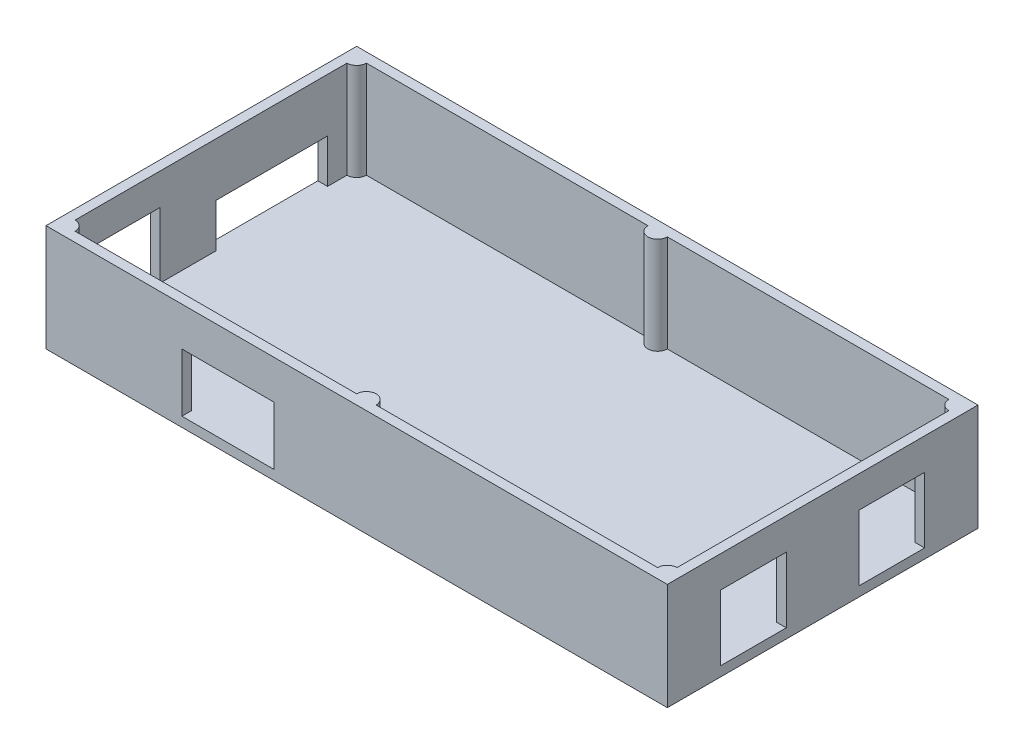
from build123d import *

# Parameters (mm, degrees)
SKETCH3_W           = 128
SKETCH3_H           = 64
BOSS_EXTRUDE1_DEPTH = 22
BOSS_EXTRUDE3_DEPTH = 2
CUT_EXTRUDE1_REACH  = 135.761
SKETCH5_W           = 13.5
SKETCH5_H           = 13.5
SKETCH6_W           = 23
SKETCH6_H           = 9
SKETCH6_W_2         = 13.5
SKETCH6_H_2         = 13.5
CUT_EXTRUDE2_DEPTH  = 2
SKETCH7_W           = 19
SKETCH7_H           = 12
CUT_EXTRUDE3_DEPTH  = 2


with BuildPart() as part:
    # Sketch3 → Boss-Extrude1 (new body)
    with BuildSketch(Plane(origin=(0, 0, 0), x_dir=(1, 0, 0), z_dir=(0, 1, 0))):
        Rectangle(SKETCH3_W, SKETCH3_H)
        with BuildLine():
            Line((2, 30), (60, 30))
            ThreePointArc((60, 30), (60.585786438, 28.585786438), (62, 28))
            Line((62, 28), (62, -28))
            ThreePointArc((62, -28), (60.585786438, -28.585786438), (60, -30))
            Line((60, -30), (2, -30))
            ThreePointArc((2, -30), (0, -28), (-2, -30))
            Line((-2, -30), (-60, -30))
            ThreePointArc((-60, -30), (-60.585786438, -28.585786438), (-62, -28))
            Line((-62, -28), (-62, 28))
            ThreePointArc((-62, 28), (-60.585786438, 28.585786438), (-60, 30))
            Line((-60, 30), (-2, 30))
            ThreePointArc((-2, 30), (0, 28), (2, 30))
        make_face(mode=Mode.SUBTRACT)
    extrude(amount=BOSS_EXTRUDE1_DEPTH)

    # Sketch3_5 → Boss-Extrude3 (add)
    with BuildSketch(Plane(origin=(0, 0, 0), x_dir=(1, 0, 0), z_dir=(0, 1, 0))):
        with BuildLine():
            ThreePointArc((62, 28), (60.585786438, 28.585786438), (60, 30))
            Line((60, 30), (2, 30))
            ThreePointArc((2, 30), (0, 28), (-2, 30))
            Line((-2, 30), (-60, 30))
            ThreePointArc((-60, 30), (-60.585786438, 28.585786438), (-62, 28))
            Line((-62, 28), (-62, -28))
            ThreePointArc((-62, -28), (-60.585786438, -28.585786438), (-60, -30))
            Line((-60, -30), (-2, -30))
            ThreePointArc((-2, -30), (0, -28), (2, -30))
            Line((2, -30), (60, -30))
            ThreePointArc((60, -30), (60.585786438, -28.585786438), (62, -28))
            Line((62, -28), (62, 28))
        make_face()
    extrude(amount=BOSS_EXTRUDE3_DEPTH)

    # Sketch5 → Cut-Extrude1 (cut, up to next)
    with BuildSketch(Plane(origin=(64, 0, 0), x_dir=(0, 0, -1), z_dir=(1, 0, 0)), mode=Mode.PRIVATE) as cut_extrude1_sk1:
        with Locations((14.25, 8.75)):
            Rectangle(SKETCH5_W, SKETCH5_H)
    cut_extrude1_tool1 = extrude(cut_extrude1_sk1.sketch, amount=-CUT_EXTRUDE1_REACH, mode=Mode.PRIVATE) & part.part
    # Sketch5 → Cut-Extrude1 (cut, up to next)
    with BuildSketch(Plane(origin=(64, 0, 0), x_dir=(0, 0, -1), z_dir=(1, 0, 0)), mode=Mode.PRIVATE) as cut_extrude1_sk2:
        with Locations((-14.25, 8.75)):
            Rectangle(SKETCH5_W, SKETCH5_H)
    cut_extrude1_tool2 = extrude(cut_extrude1_sk2.sketch, amount=-CUT_EXTRUDE1_REACH, mode=Mode.PRIVATE) & part.part
    add(cut_extrude1_tool1.solids().sort_by_distance((64, 8.75, -14.25))[0], mode=Mode.SUBTRACT)
    add(cut_extrude1_tool2.solids().sort_by_distance((64, 8.75, 14.25))[0], mode=Mode.SUBTRACT)

    # Sketch6 → Cut-Extrude2 (cut)
    with BuildSketch(Plane.ZY.offset(64)):
        with Locations((-12.5, 6.5)):
            Rectangle(SKETCH6_W, SKETCH6_H)
        with Locations((17.25, 8.75)):
            Rectangle(SKETCH6_W_2, SKETCH6_H_2)
    extrude(amount=-CUT_EXTRUDE2_DEPTH, mode=Mode.SUBTRACT)

    # Sketch7 → Cut-Extrude3 (cut)
    with BuildSketch(Plane.XY.offset(32)):
        with Locations((-26.5, 8)):
            Rectangle(SKETCH7_W, SKETCH7_H)
    extrude(amount=-CUT_EXTRUDE3_DEPTH, mode=Mode.SUBTRACT)


solid = part.part
